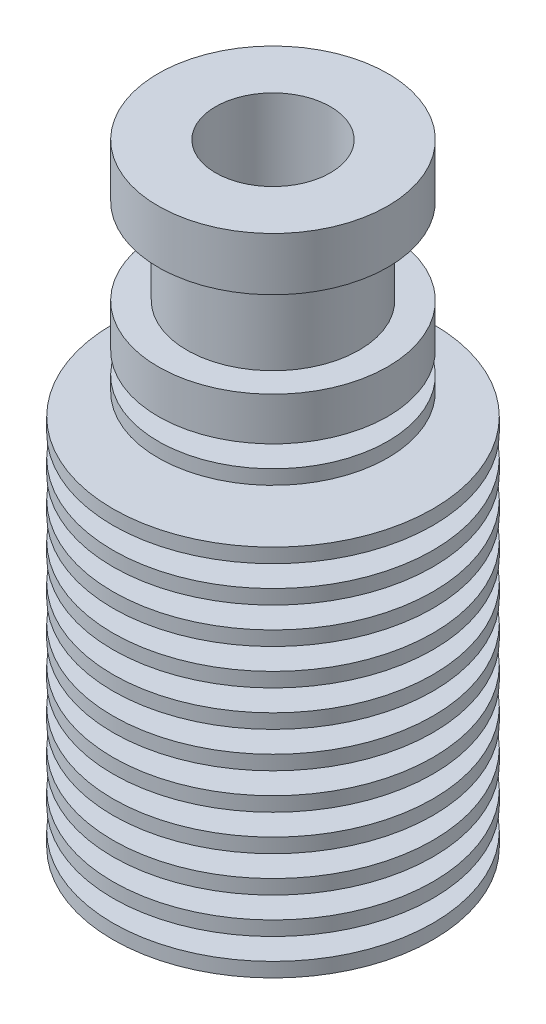
from build123d import *

# Parameters (mm, degrees)
TAP_DRILL_FOR_M7X1_0_TAP3_D     = 6
TAP_DRILL_FOR_M7X1_0_TAP3_DEPTH = 10.5


with BuildPart() as part:
    # Sketch1 → Revolve1 (revolve)
    with BuildSketch(Plane.XY):
        Polygon((0, 0), (-8, 0), (-8, -3.7), (-6, -3.7), (-6, -9.7), (-8, -9.7), (-8, -12.7), (-4.5, -12.7), (-4.5, -14.2), (-8, -14.2), (-8, -15.2), (-4.659090909, -15.2), (-4.659090909, -16.7), (-11.15, -16.7), (-11.15, -17.7), (-4.818181818, -17.7), (-4.818181818, -19.2), (-11.15, -19.2), (-11.15, -20.2), (-4.977272727, -20.2), (-4.977272727, -21.7), (-11.15, -21.7), (-11.15, -22.7), (-5.136363636, -22.7), (-5.136363636, -24.2), (-11.15, -24.2), (-11.15, -25.2), (-5.295454545, -25.2), (-5.295454545, -26.7), (-11.15, -26.7), (-11.15, -27.7), (-5.454545455, -27.7), (-5.454545455, -29.2), (-11.15, -29.2), (-11.15, -30.2), (-5.613636364, -30.2), (-5.613636364, -31.7), (-11.15, -31.7), (-11.15, -32.7), (-5.772727273, -32.7), (-5.772727273, -34.2), (-11.15, -34.2), (-11.15, -35.2), (-5.931818182, -35.2), (-5.931818182, -36.7), (-11.15, -36.7), (-11.15, -37.7), (-6.090909091, -37.7), (-6.090909091, -39.2), (-11.15, -39.2), (-11.15, -40.2), (-6.25, -40.2), (-6.25, -41.7), (-11.15, -41.7), (-11.15, -42.7), (0, -42.7), align=None)
    revolve(axis=Axis((0, -42.7, 0), (0, 1, 0)))

    # Tap Drill for M7x1.0 Tap3
    with Locations(Plane(origin=(0, -42.7, 0), x_dir=(-1, 0, 0), z_dir=(0, -1, 0))):
        with Locations((0, 0)):
            Hole(TAP_DRILL_FOR_M7X1_0_TAP3_D / 2, depth=TAP_DRILL_FOR_M7X1_0_TAP3_DEPTH)

    # Sketch1_4 → Cut-Revolve1 (revolve, cut)
    with BuildSketch(Plane.XY):
        Polygon((0, -42.7), (0, 0), (-4, 0), (-4, -6.5), (-2, -7.654700538), (-2, -27.29955572), (-2, -42.7), align=None)
    revolve(axis=Axis((0, -42.7, 0), (0, 1, 0)), mode=Mode.SUBTRACT)


solid = part.part
